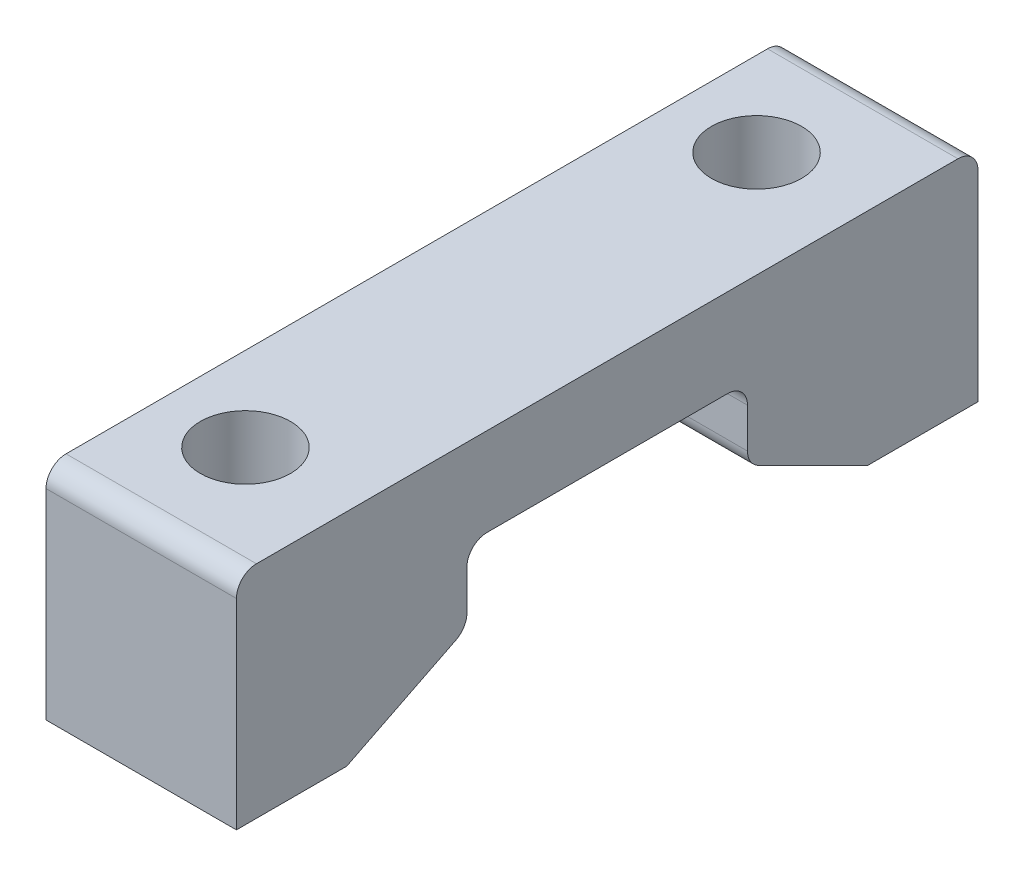
from build123d import *

# Parameters (mm, degrees)
BOSS_EXTRUDE1_DEPTH = 9.5
SKETCH2_R           = 2.25
CUT_EXTRUDE1_DEPTH  = 12
FILLET1_R           = 1


with BuildPart() as part:
    # Sketch1 → Boss-Extrude1 (new body)
    with BuildSketch(Plane(origin=(0, 0, 0), x_dir=(0, 0, -1), z_dir=(1, 0, 0))):
        Polygon((-7, 1.1), (7, 1.1), (7, -2.5), (13, -5.5), (18.5, -5.5), (18.5, 5.5), (-18.5, 5.5), (-18.5, -5.5), (-13, -5.5), (-7, -2.5), align=None)
    extrude(amount=BOSS_EXTRUDE1_DEPTH)

    # Sketch2 → Cut-Extrude1 (cut, through all)
    with BuildSketch(Plane(origin=(0, 5.5, 0), x_dir=(1, 0, 0), z_dir=(0, 1, 0))):
        with Locations((4.2, -12.75)):
            Circle(SKETCH2_R)
        with Locations((4.2, 12.75)):
            Circle(SKETCH2_R)
    extrude(amount=-CUT_EXTRUDE1_DEPTH, mode=Mode.SUBTRACT)

    # Fillet1
    fillet1_edges = [part.edges().sort_by_distance(p)[0] for p in [
        (4.75, 5.5, 18.5),
        (4.75, 5.5, -18.5),
        (4.75, -2.5, -7),
        (4.75, 1.1, -7),
        (4.75, 1.1, 7),
        (4.75, -2.5, 7),
    ]]
    fillet(fillet1_edges, radius=FILLET1_R)


solid = part.part
